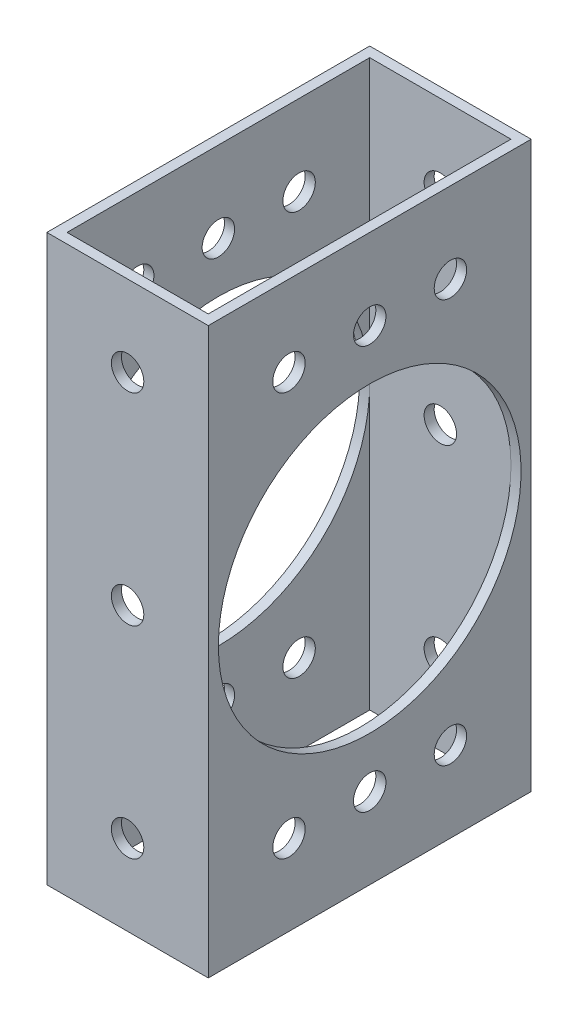
from build123d import *

# Parameters (mm, degrees)
SKETCH1_W              = 25.4
SKETCH1_H              = 50.8
SKETCH1_W_2            = 22.225
SKETCH1_H_2            = 47.625
EXTRUDE_THIN1_DEPTH    = 88.9
F_10_CLEARANCE_HOLE1_D = 5.1054
F_10_CLEARANCE_HOLE2_D = 5.1054
SKETCH8_R              = 23.8125
CUT_EXTRUDE1_DEPTH     = 26.4


with BuildPart() as part:
    # Sketch1 → Extrude-Thin1 (new body)
    with BuildSketch(Plane(origin=(0, 0, 0), x_dir=(1, 0, 0), z_dir=(0, 1, 0))):
        Rectangle(SKETCH1_W, SKETCH1_H)
        Rectangle(SKETCH1_W_2, SKETCH1_H_2, mode=Mode.SUBTRACT)
    extrude(amount=EXTRUDE_THIN1_DEPTH)

    # #10 Clearance Hole1 (through all)
    with Locations(Plane.ZY.offset(12.7)):
        with Locations((-12.7, 76.2), (0, 76.2), (12.7, 76.2), (-12.7, 12.7), (0, 12.7), (12.7, 12.7)):
            Hole(F_10_CLEARANCE_HOLE1_D / 2)

    # #10 Clearance Hole2 (through all)
    with Locations(Plane.XY.offset(25.4)):
        with Locations((0, 12.7), (0, 76.2), (0, 44.45)):
            Hole(F_10_CLEARANCE_HOLE2_D / 2)

    # Sketch8 → Cut-Extrude1 (cut, through all)
    with BuildSketch(Plane.ZY.offset(12.7)):
        with Locations((0, 44.45)):
            Circle(SKETCH8_R)
    extrude(amount=-CUT_EXTRUDE1_DEPTH, mode=Mode.SUBTRACT)


solid = part.part
